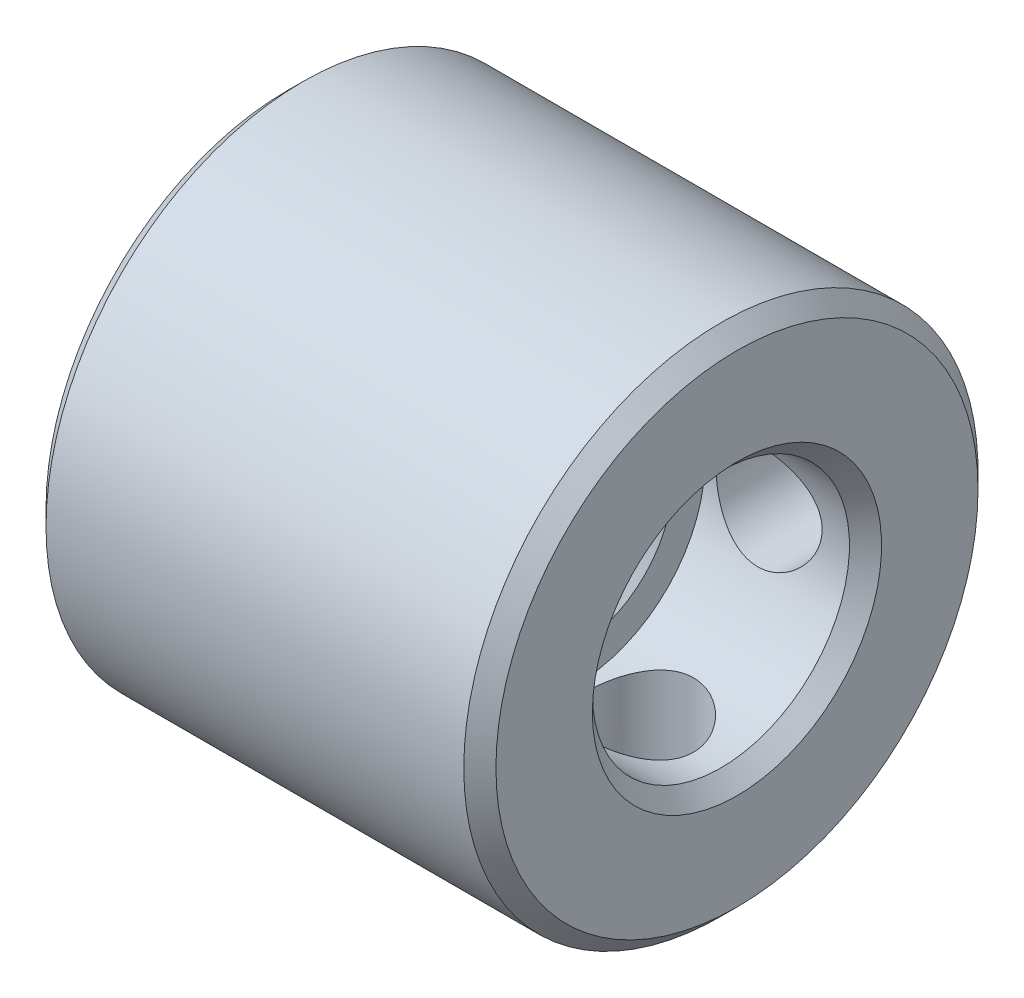
from build123d import *

# Parameters (mm, degrees)
CHAMFER_1_SIZE      = 0.5
SKETCH_2_R          = 1.65
CUT_EXTRUDE_1_DEPTH = 10
SKETCH_3_R          = 1.65
CUT_EXTRUDE_2_DEPTH = 10


with BuildPart() as part:
    # 草图1 → 旋转1 (revolve)
    with BuildSketch(Plane(origin=(0, 0, 0), x_dir=(1, 0, 0), z_dir=(0, 1, 0))):
        Polygon((14, 8), (0, 8), (0, 2.5), (9, 2.5), (9, 4), (14, 4), align=None)
    revolve(axis=Axis((-5, 0, 0), (1, 0, 0)))

    # 倒角1
    chamfer_1_edges = [part.edges().sort_by_distance(p)[0] for p in [
        (14, 0, 4),
        (9, 0, 2.5),
        (0, 0, 2.5),
        (0, 0, 8),
        (14, 0, 8),
    ]]
    chamfer(chamfer_1_edges, length=CHAMFER_1_SIZE)

    # 草图2 → 切除-拉伸1 (cut)
    with BuildSketch(Plane(origin=(0, 0, 0), x_dir=(1, 0, 0), z_dir=(0, 1, 0))):
        with Locations((3, 0)):
            Circle(SKETCH_2_R)
        with Locations((11, 0)):
            Circle(SKETCH_2_R)
    extrude(amount=-CUT_EXTRUDE_1_DEPTH, mode=Mode.SUBTRACT)

    # 草图3 → 切除-拉伸2 (cut)
    with BuildSketch(Plane.XY):
        with Locations((3, 0)):
            Circle(SKETCH_3_R)
        with Locations((11, 0)):
            Circle(SKETCH_3_R)
    extrude(amount=-CUT_EXTRUDE_2_DEPTH, mode=Mode.SUBTRACT)


solid = part.part
